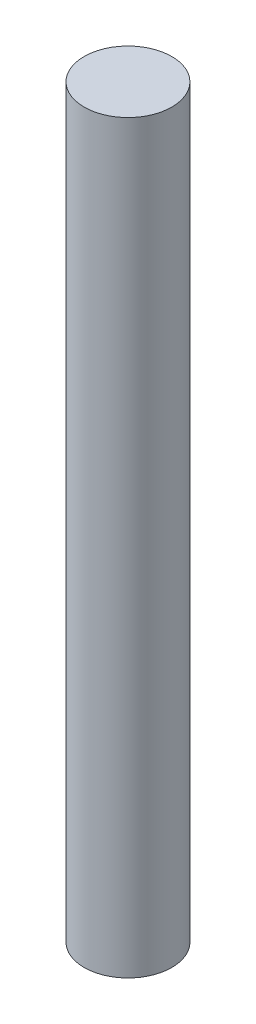
from build123d import *

# Parameters (mm, degrees)
SKETCH1_R           = 2
BOSS_EXTRUDE1_DEPTH = 34


with BuildPart() as part:
    # Sketch1 → Boss-Extrude1 (new body)
    with BuildSketch(Plane(origin=(0, 0, 0), x_dir=(1, 0, 0), z_dir=(0, 1, 0))):
        Circle(SKETCH1_R)
    extrude(amount=BOSS_EXTRUDE1_DEPTH)


solid = part.part
